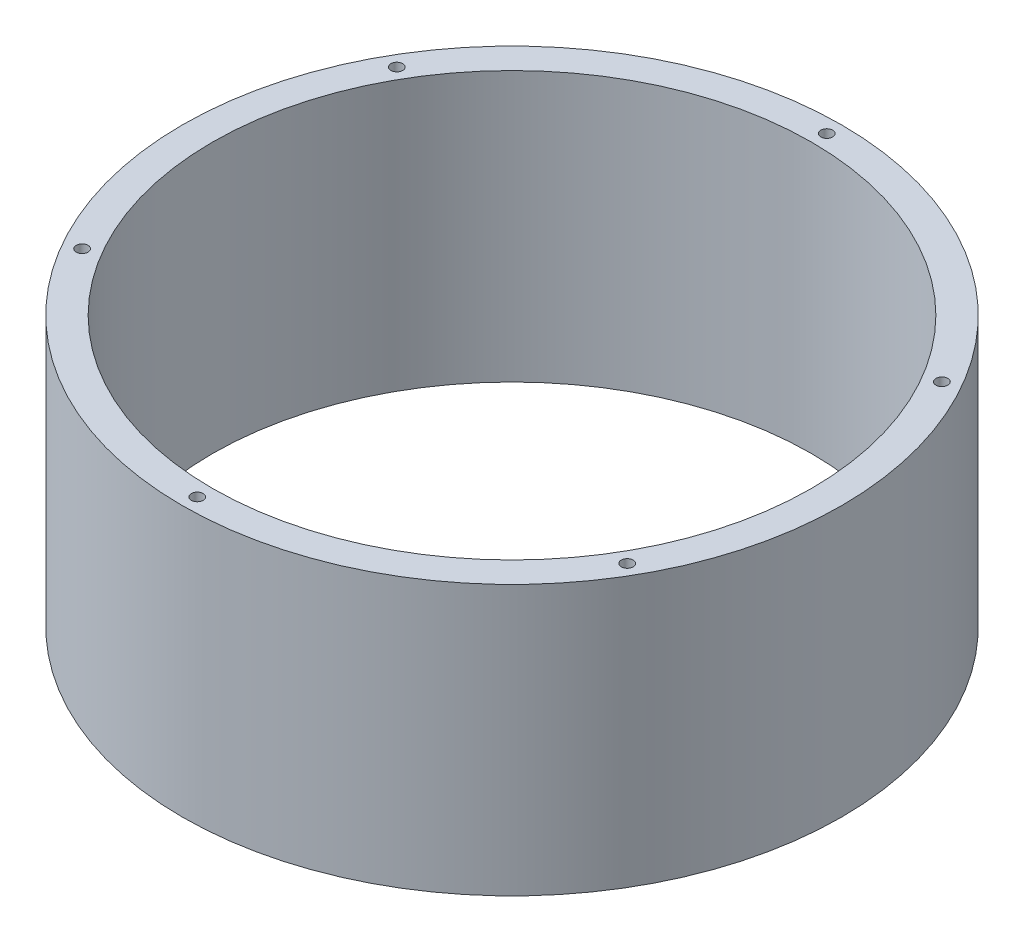
from build123d import *

# Parameters (mm, degrees)
SKETCH1_R         = 69.85
SKETCH1_R_2       = 63.5
EXTRUDE1_DEPTH    = 57.15
CIRPATTERN1_COUNT = 6
CIRPATTERN2_COUNT = 6


with BuildPart() as part:
    # Sketch1 → Extrude1 (new body)
    with BuildSketch(Plane(origin=(0, 0, 0), x_dir=(1, 0, 0), z_dir=(0, 1, 0))):
        Circle(SKETCH1_R)
        Circle(SKETCH1_R_2, mode=Mode.SUBTRACT)
    extrude(amount=EXTRUDE1_DEPTH)

    # Sketch5 → 3-56 Tapped Hole1 (revolve, cut)
    with BuildSketch(Plane(origin=(0, 0, 66.675), x_dir=(0, 0, -1), z_dir=(1, 0, 0))):
        Polygon((0, 0), (0, 6.975736249), (1.0414, 6.35), (1.0414, 5.08), (1.2573, 5.08), (1.2573, 0), align=None)
    f_3_56_tapped_hole1 = revolve(axis=Axis((0, -6.35, 66.675), (0, 1, 0)), mode=Mode.SUBTRACT)

    # CirPattern1: 3-56 Tapped Hole1 ×6 about axis
    cirpattern1_axis = Axis((0, 65.196659439, 0), (0, -1, 0))
    for i in range(1, CIRPATTERN1_COUNT):
        add(f_3_56_tapped_hole1.rotate(cirpattern1_axis, i * 360 / CIRPATTERN1_COUNT), mode=Mode.SUBTRACT)

    # Sketch6 → 3-56 Tapped Hole2 (revolve, cut)
    with BuildSketch(Plane(origin=(0.005576043, 57.15, -66.674999767), x_dir=(0, 0, 1), z_dir=(1, 0, 0))):
        Polygon((0, 0), (0, 7.026536249), (1.0414, 6.4008), (1.0414, 5.0292), (1.2573, 5.0292), (1.2573, 0), align=None)
    f_3_56_tapped_hole2 = revolve(axis=Axis((0.005576043, 63.5, -66.674999767), (0, -1, 0)), mode=Mode.SUBTRACT)

    # CirPattern2: 3-56 Tapped Hole2 ×6 about axis
    cirpattern2_axis = Axis((0, 65.196659439, 0), (0, -1, 0))
    for i in range(1, CIRPATTERN2_COUNT):
        add(f_3_56_tapped_hole2.rotate(cirpattern2_axis, i * 360 / CIRPATTERN2_COUNT), mode=Mode.SUBTRACT)


solid = part.part
